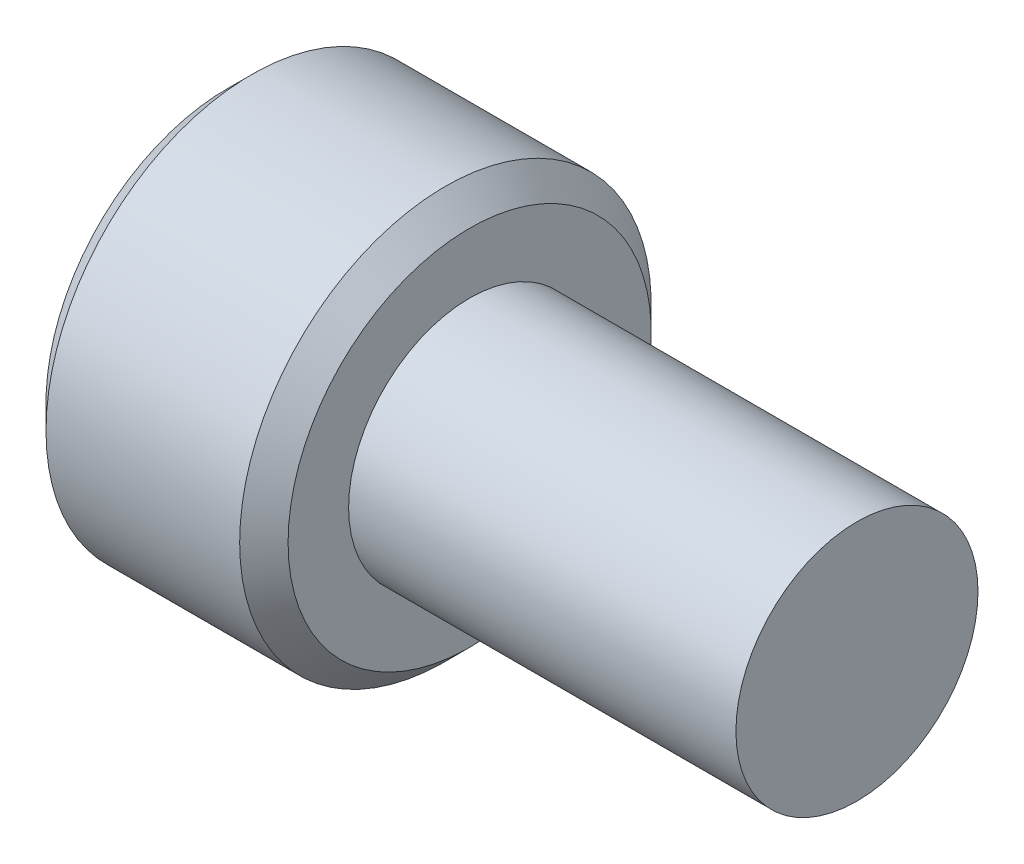
from build123d import *

# Parameters (mm, degrees)
CUT_EXTRUDE1_DEPTH = 2
CHAMFER1_SIZE      = 0.5


with BuildPart() as part:
    # Sketch1 → Revolve1 (revolve)
    with BuildSketch(Plane.XY):
        Polygon((0, 2.5), (8, 2.5), (8, 0), (-5, 0), (-5, 4.25), (0, 4.25), align=None)
    revolve(axis=Axis((-10.4, 0, 0), (1, 0, 0)))

    # Sketch2 → Cut-Revolve1 (revolve, cut)
    with BuildSketch(Plane.XY):
        Polygon((-1.798278762, 0), (-3, 2), (-5, 2), (-5, 0), align=None)
    revolve(axis=Axis((-10.4, 0, 0), (1, 0, 0)), mode=Mode.SUBTRACT)

    # Sketch3 → Cut-Extrude1 (cut)
    with BuildSketch(Plane.ZY.offset(5)):
        Polygon((2, 1.154700538), (0, 2.309401077), (-2, 1.154700538), (-2, -1.154700538), (0, -2.309401077), (2, -1.154700538), align=None)
    extrude(amount=-CUT_EXTRUDE1_DEPTH, mode=Mode.SUBTRACT)

    # Chamfer1
    chamfer1_edges = [part.edges().sort_by_distance(p)[0] for p in [
        (0, -4.25, 0),
        (-5, -4.25, 0),
    ]]
    chamfer(chamfer1_edges, length=CHAMFER1_SIZE)


solid = part.part
